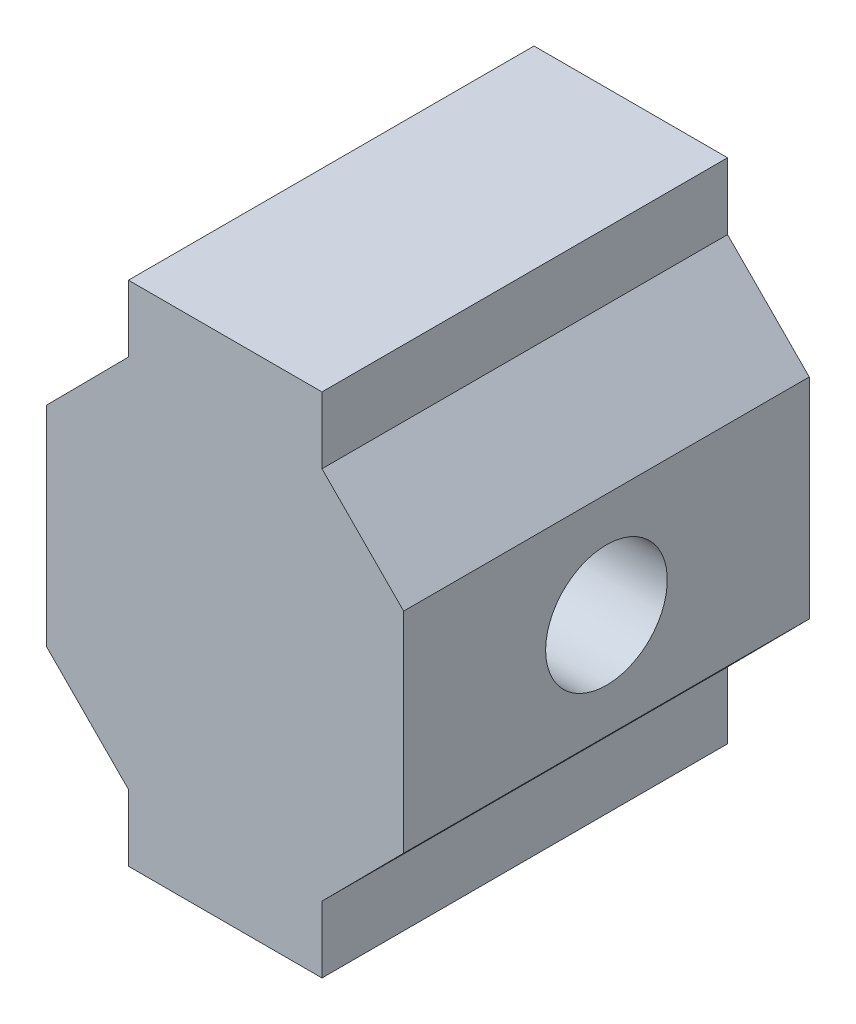
from build123d import *

# Parameters (mm, degrees)
BOSS_EXTRUDE1_DEPTH     = 20
SKETCH2_R               = 3
CUT_EXTRUDE1_DEPTH      = 20
CUT_EXTRUDE1_DEPTH_BACK = 20
SKETCH3_R               = 1.95
CUT_EXTRUDE2_DEPTH      = 6


with BuildPart() as part:
    # Sketch1 → Boss-Extrude1 (new body)
    with BuildSketch(Plane.XY):
        Polygon((4.772, -12.514), (4.772, -9.231678019), (8.8, -5.167678019), (8.8, 0), (8.8, 5.167678019), (4.772, 9.231678019), (4.772, 12.514), (-4.772, 12.514), (-4.772, 9.231678019), (-8.8, 5.167678019), (-8.8, 0), (-8.8, -5.167678019), (-4.772, -9.231678019), (-4.772, -12.514), align=None)
    extrude(amount=BOSS_EXTRUDE1_DEPTH)

    # Sketch2 → Cut-Extrude1 (cut, two sides)
    with BuildSketch(Plane(origin=(0, 0, 0), x_dir=(0, 0, -1), z_dir=(1, 0, 0))) as cut_extrude1_sk:
        with Locations((-10, 0)):
            Circle(SKETCH2_R)
    extrude(amount=CUT_EXTRUDE1_DEPTH, mode=Mode.SUBTRACT)
    extrude(cut_extrude1_sk.sketch, amount=-CUT_EXTRUDE1_DEPTH_BACK, mode=Mode.SUBTRACT)

    # Sketch3 → Cut-Extrude2 (cut)
    with BuildSketch(Plane(origin=(0, 0, 0), x_dir=(-1, 0, 0), z_dir=(0, 0, -1))):
        Circle(SKETCH3_R)
    extrude(amount=-CUT_EXTRUDE2_DEPTH, mode=Mode.SUBTRACT)


solid = part.part
